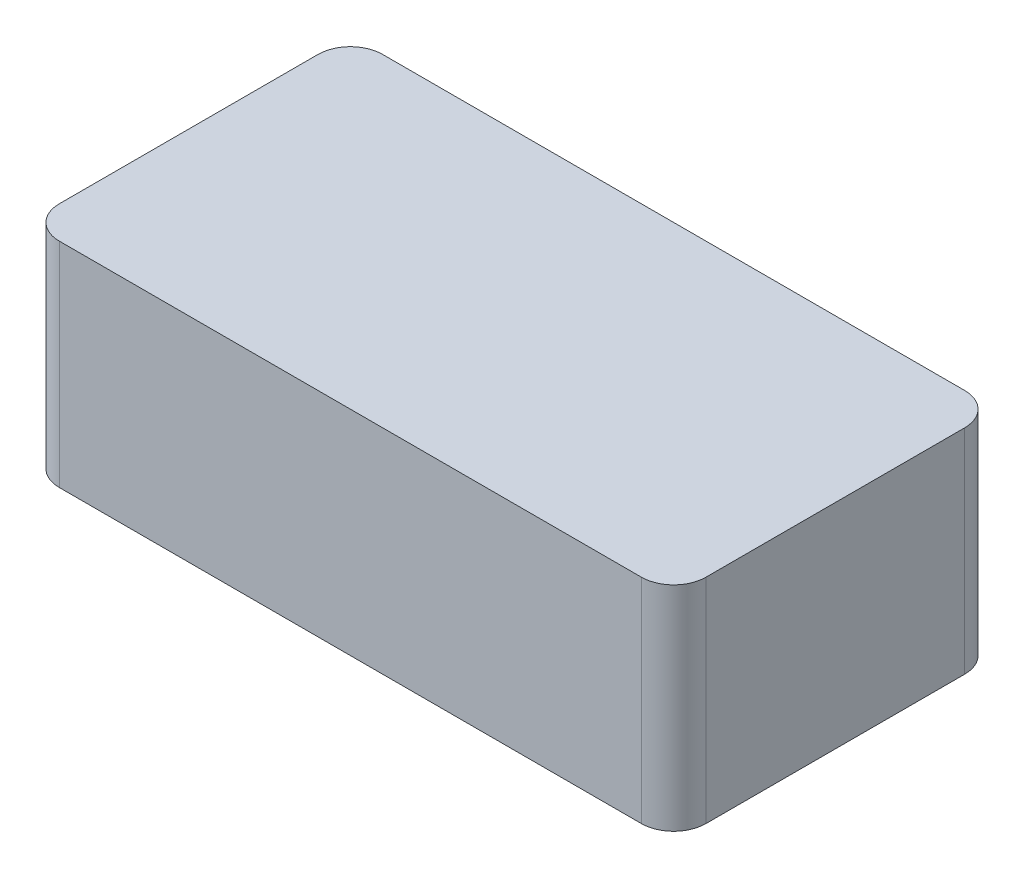
from build123d import *

# Parameters (mm, degrees)
SKETCH1_W           = 40
SKETCH1_H           = 20
BOSS_EXTRUDE1_DEPTH = 13.2
FILLET1_R           = 2


with BuildPart() as part:
    # Sketch1 → Boss-Extrude1 (new body)
    with BuildSketch(Plane(origin=(0, 0, 0), x_dir=(1, 0, 0), z_dir=(0, 1, 0))):
        with Locations((20, 10)):
            Rectangle(SKETCH1_W, SKETCH1_H)
    extrude(amount=BOSS_EXTRUDE1_DEPTH)

    # Fillet1
    fillet1_edges = [part.edges().sort_by_distance(p)[0] for p in [
        (0, 6.6, -20),
        (40, 6.6, -20),
        (40, 6.6, 0),
        (0, 6.6, 0),
    ]]
    fillet(fillet1_edges, radius=FILLET1_R)


solid = part.part
